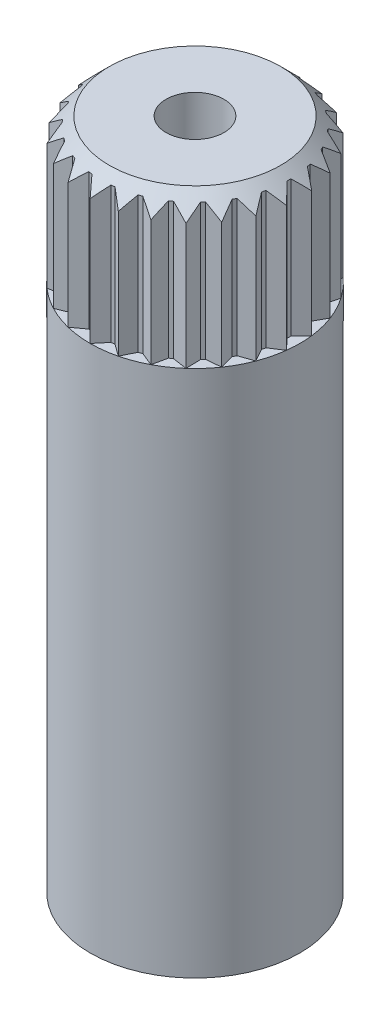
from build123d import *

# Parameters (mm, degrees)
SHAFTS_R              = 2.9
SHAFT_DEPTH           = 14.6
SHAFTEXTENSIONS_R     = 2.6
SHAFT_EXTENSION_DEPTH = 4
TOOTH_DEPTH           = 18.6
TOOTH_CP_COUNT        = 26
SMALLBORES_R          = 0.8
SMALL_BORE_DEPTH      = 4


with BuildPart() as part:
    # ShaftS → SHAFT (new body)
    with BuildSketch(Plane(origin=(0, 0, 0), x_dir=(1, 0, 0), z_dir=(0, 1, 0))):
        Circle(SHAFTS_R)
    extrude(amount=SHAFT_DEPTH)

    # ShaftExtensionS → SHAFT EXTENSION (add)
    with BuildSketch(Plane(origin=(0, 14.6, 0), x_dir=(1, 0, 0), z_dir=(0, 1, 0))):
        Circle(SHAFTEXTENSIONS_R)
    extrude(amount=SHAFT_EXTENSION_DEPTH)

    # ToothS → TOOTH (add)
    with BuildSketch(Plane(origin=(0, 18.6, 0), x_dir=(1, 0, 0), z_dir=(0, 1, 0))):
        with BuildLine():
            Line((0, 2.9), (-0.262912611, 2.586672952))
            ThreePointArc((-0.262912611, 2.586672952), (0, 2.6), (0.262912611, 2.586672952))
            Line((0.262912611, 2.586672952), (0, 2.9))
        make_face()
    tooth = extrude(amount=-TOOTH_DEPTH)

    # TOOTH CP: TOOTH ×26 about axis
    tooth_cp_axis = Axis((0, 0, 0), (0, 1, 0))
    for i in range(1, TOOTH_CP_COUNT):
        add(tooth.rotate(tooth_cp_axis, i * 360 / TOOTH_CP_COUNT))

    # SmallBoreS → SMALL BORE (cut)
    with BuildSketch(Plane(origin=(0, 18.6, 0), x_dir=(1, 0, 0), z_dir=(0, 1, 0))):
        Circle(SMALLBORES_R)
    extrude(amount=-SMALL_BORE_DEPTH, mode=Mode.SUBTRACT)

    # TeethChamferS → TEETH CHAMFER (revolve, cut)
    with BuildSketch(Plane(origin=(0, 0, 0), x_dir=(0, 0, -1), z_dir=(1, 0, 0))):
        Polygon((2.9, 18.069669914), (2.9, 18.6), (2.369669914, 18.6), align=None)
    revolve(axis=Axis((0, 18.6, 0), (0, -1, 0)), mode=Mode.SUBTRACT)


solid = part.part
